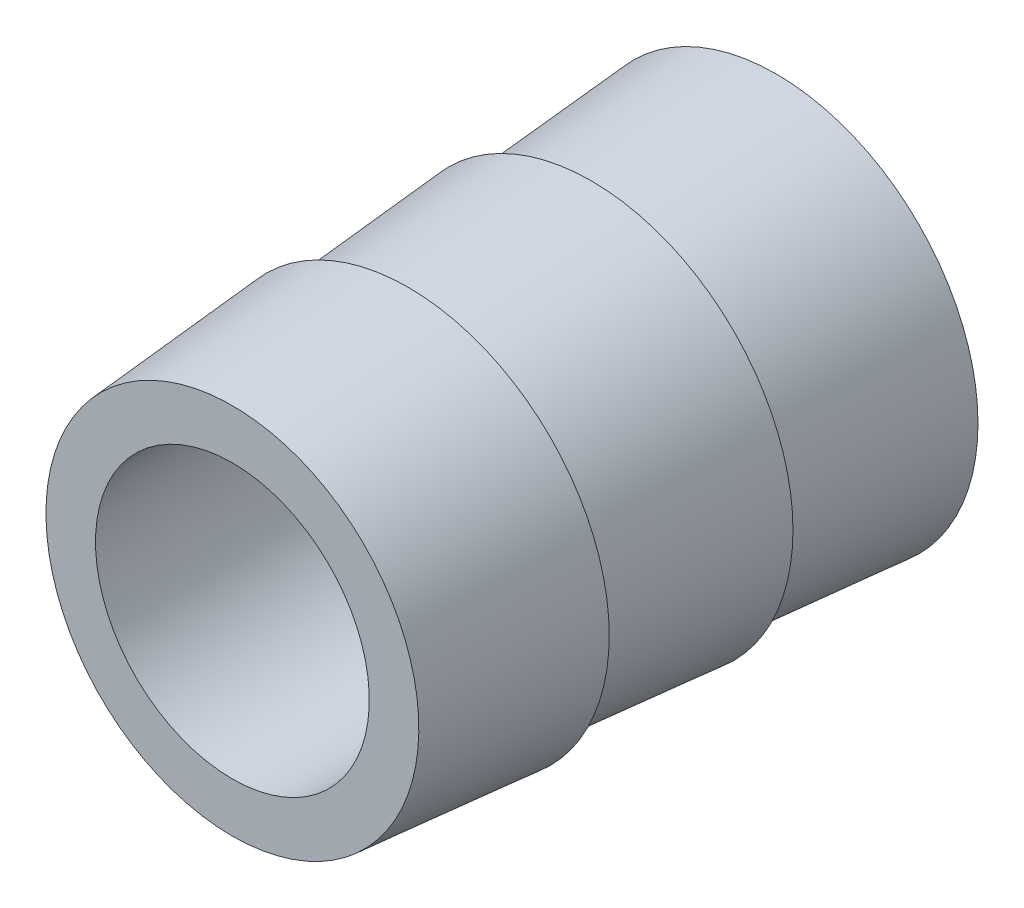
from build123d import *

# Parameters (mm, degrees)
SKETCH7_R          = 2.75
CUT_EXTRUDE3_DEPTH = 11.926156548


with BuildPart() as part:
    # Sketch2 → Revolve2 (revolve)
    with BuildSketch(Plane(origin=(0, 0, 0), x_dir=(0, 0, -1), z_dir=(1, 0, 0))):
        Polygon((-0.541748287, -1.269840707), (6.851295576, -1.269840707), (6.851295576, 1.28177138), (6.851295576, 2.78177138), (3.137110203, 2.486943896), (3.137110203, 1.279043896), (3.137110203, 2.779043896), (-0.541748287, 2.475013223), (-0.541748287, 1.267113223), (-0.541748287, 2.767113223), (-4.074860971, 2.475127372), (-4.074860971, 0.975127372), (-4.074860971, -1.269840707), align=None)
    revolve(axis=Axis((0, -1.269840707, 0.541748287), (0, 0, -1)))

    # Sketch7 → Cut-Extrude3 (cut, through all)
    with BuildSketch(Plane(origin=(0, 0, -6.851295576), x_dir=(-1, 0, 0), z_dir=(0, 0, -1))):
        with Locations((0, -1.269840707)):
            Circle(SKETCH7_R)
    extrude(amount=-CUT_EXTRUDE3_DEPTH, mode=Mode.SUBTRACT)


solid = part.part
